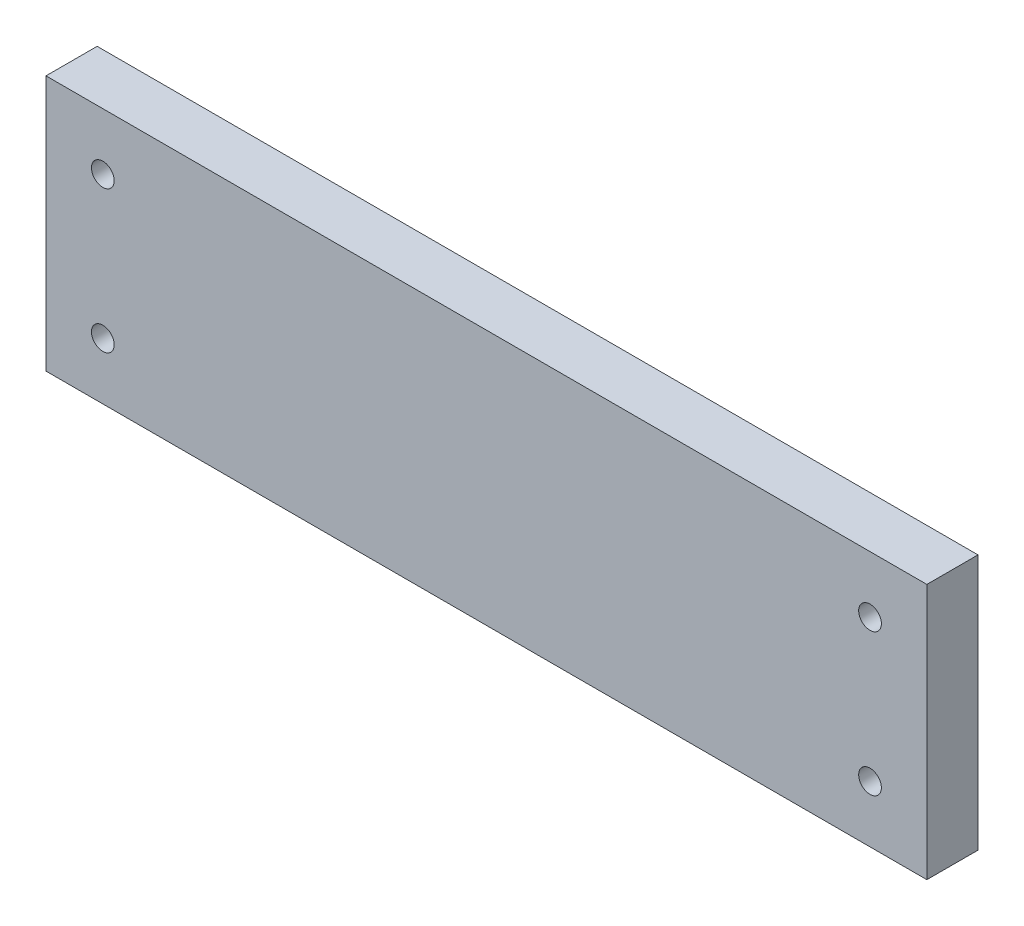
from build123d import *

# Parameters (mm, degrees)
SKETCH1_W           = 310
SKETCH1_H           = 90
BOSS_EXTRUDE1_DEPTH = 18
SKETCH2_R           = 4
CUT_EXTRUDE1_DEPTH  = 23


with BuildPart() as part:
    # Sketch1 → Boss-Extrude1 (new body)
    with BuildSketch(Plane.XY):
        with Locations((-109.503554368, 58.028908165)):
            Rectangle(SKETCH1_W, SKETCH1_H)
    extrude(amount=BOSS_EXTRUDE1_DEPTH)

    # Sketch2 → Cut-Extrude1 (cut)
    with BuildSketch(Plane.XY.offset(18)):
        with Locations((-244.503554368, 33.028908165)):
            Circle(SKETCH2_R)
        with Locations((25.496445632, 33.028908165)):
            Circle(SKETCH2_R)
        with Locations((25.496445632, 83.028908165)):
            Circle(SKETCH2_R)
        with Locations((-244.503554368, 83.028908165)):
            Circle(SKETCH2_R)
    extrude(amount=-CUT_EXTRUDE1_DEPTH, mode=Mode.SUBTRACT)


solid = part.part
